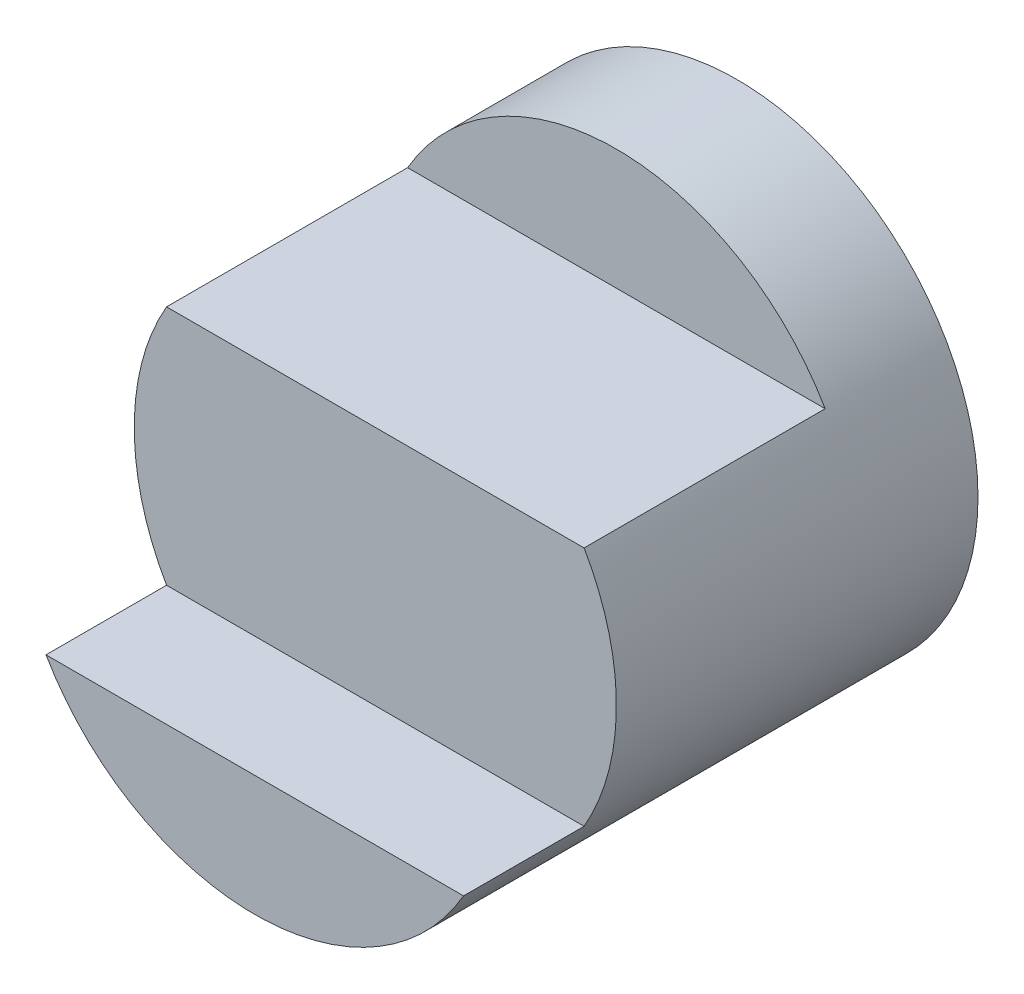
from build123d import *

# Parameters (mm, degrees)
SKETCH1_R           = 2
BOSS_EXTRUDE1_DEPTH = 4
BOSS_EXTRUDE2_DEPTH = 1
CUT_EXTRUDE1_DEPTH  = 3
CUT_EXTRUDE2_DEPTH  = 6


with BuildPart() as part:
    # Sketch1 → Boss-Extrude1 (new body)
    with BuildSketch(Plane.XY):
        Circle(SKETCH1_R)
    extrude(amount=BOSS_EXTRUDE1_DEPTH)

    # Sketch2 → Boss-Extrude2 (add)
    with BuildSketch(Plane.XY.offset(4)):
        with BuildLine():
            Line((-1.732050808, -1), (1.732050808, -1))
            ThreePointArc((1.732050808, -1), (0, -2), (-1.732050808, -1))
        make_face()
    extrude(amount=BOSS_EXTRUDE2_DEPTH)

    # Sketch3 → Cut-Extrude1 (cut)
    with BuildSketch(Plane.XY.offset(4)):
        with BuildLine():
            Line((-1.732050808, 1), (1.732050808, 1))
            ThreePointArc((1.732050808, 1), (0, 2), (-1.732050808, 1))
        make_face()
    extrude(amount=-CUT_EXTRUDE1_DEPTH, mode=Mode.SUBTRACT)

    # Sketch4 → Cut-Extrude2 (cut, symmetric)
    with BuildSketch(Plane(origin=(0, 0, 0), x_dir=(0, 0, -1), z_dir=(1, 0, 0))):
        Polygon((-4, -1), (-3, -1), (-3, 1), (-3, 1.7578402), (-5.763570066, 1.806323886), (-6.032923873, -1.975403573), (-4.341381962, -2.24475738), (-4, -2.24475738), align=None)
    extrude(amount=CUT_EXTRUDE2_DEPTH, both=True, mode=Mode.SUBTRACT)


solid = part.part
